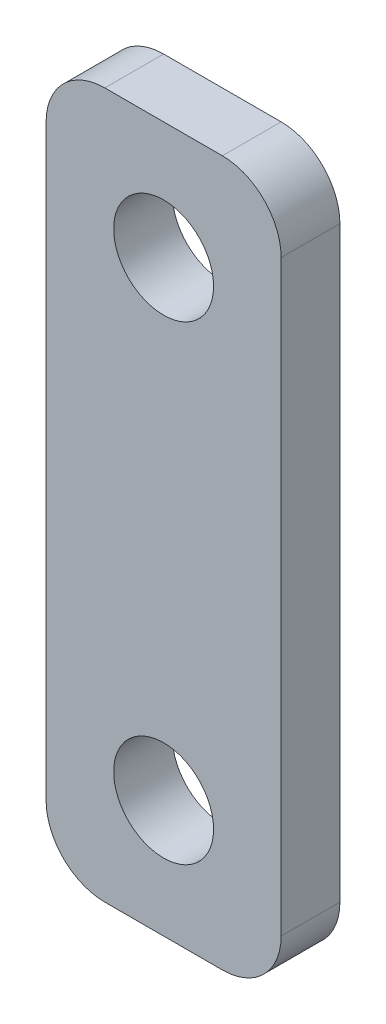
from build123d import *

# Parameters (mm, degrees)
ESQUISSE1_W             = 40
ESQUISSE1_H             = 120
BOSS_EXTRU_1_DEPTH      = 5
ESQUISSE2_R             = 8.5
ENL_V_MAT_EXTRU_1_DEPTH = 11
CONG_1_R                = 10


with BuildPart() as part:
    # Esquisse1 → Boss.-Extru.1 (new body, symmetric)
    with BuildSketch(Plane.XY):
        with Locations((70, 0)):
            Rectangle(ESQUISSE1_W, ESQUISSE1_H)
    extrude(amount=BOSS_EXTRU_1_DEPTH, both=True)

    # Esquisse2 → Enlèv. mat.-Extru.1 (cut, through all)
    with BuildSketch(Plane.XY.offset(5)):
        with Locations((70, 40)):
            Circle(ESQUISSE2_R)
        with Locations((70, -40)):
            Circle(ESQUISSE2_R)
    extrude(amount=-ENL_V_MAT_EXTRU_1_DEPTH, mode=Mode.SUBTRACT)

    # Congé1
    cong_1_edges = [part.edges().sort_by_distance(p)[0] for p in [
        (50, 60, 0),
        (90, 60, 0),
        (90, -60, 0),
        (50, -60, 0),
    ]]
    fillet(cong_1_edges, radius=CONG_1_R)


solid = part.part
